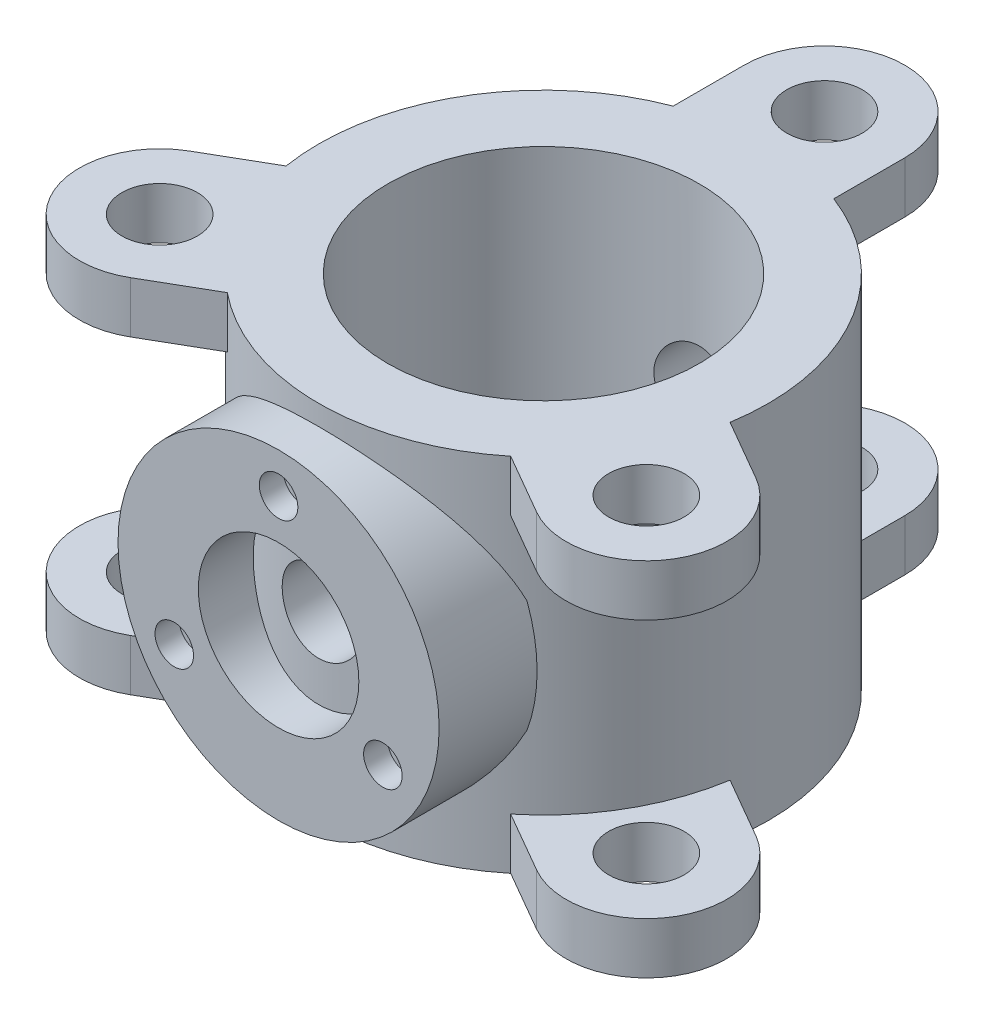
from build123d import *

# Parameters (mm, degrees)
SKETCH1_R            = 97
BOSS_EXTRUDE7_DEPTH  = 225
SKETCH1_5_R          = 23.5
BOSS_EXTRUDE9_DEPTH  = 32
SKETCH2_R            = 100
SKETCH2_R_2          = 50
BOSS_EXTRUDE11_DEPTH = 61
SKETCH2_4_R          = 12
CUT_EXTRUDE1_DEPTH   = 15
SKETCH2_5_R          = 25
CUT_EXTRUDE2_DEPTH   = 547


with BuildPart() as part:
    # Sketch1 → Boss-Extrude7 (new body)
    with BuildSketch(Plane(origin=(0, 0, 0), x_dir=(1, 0, 0), z_dir=(0, 1, 0))):
        with BuildLine():
            ThreePointArc((140, 0), (115.325625947, 79.372539332), (50, 130.766968306))
            ThreePointArc((50, 130.766968306), (0, 140), (-50, 130.766968306))
            ThreePointArc((-50, 130.766968306), (-121.24355653, 70), (-138.247516529, -22.082213964))
            ThreePointArc((-138.247516529, -22.082213964), (-121.24355653, -70), (-88.247516529, -108.684754342))
            ThreePointArc((-88.247516529, -108.684754342), (0, -140), (88.247516529, -108.684754342))
            ThreePointArc((88.247516529, -108.684754342), (121.24355653, -70), (138.247516529, -22.082213964))
            ThreePointArc((138.247516529, -22.082213964), (139.561191443, -11.075822451), (140, 0))
        make_face()
        Circle(SKETCH1_R, mode=Mode.SUBTRACT)
    extrude(amount=BOSS_EXTRUDE7_DEPTH)

    # Sketch1_5 → Boss-Extrude9 (add)
    # profile 1 of 3: a face of its own
    with BuildSketch(Plane(origin=(0, 0, 0), x_dir=(1, 0, 0), z_dir=(0, 1, 0))):
        with BuildLine():
            Line((50, 130.766968306), (50, 175))
            ThreePointArc((50, 175), (0, 225), (-50, 175))
            Line((-50, 175), (-50, 130.766968306))
            ThreePointArc((-50, 130.766968306), (0, 140), (50, 130.766968306))
        make_face()
        with Locations((0, 175)):
            Circle(SKETCH1_5_R, mode=Mode.SUBTRACT)
    # profile 2 of 3: a face of its own
    with BuildSketch(Plane(origin=(0, 0, 0), x_dir=(1, 0, 0), z_dir=(0, 1, 0))):
        with BuildLine():
            Line((176.554445662, -44.198729811), (138.247516529, -22.082213964))
            ThreePointArc((138.247516529, -22.082213964), (121.24355653, -70), (88.247516529, -108.684754342))
            Line((88.247516529, -108.684754342), (126.554445662, -130.801270189))
            ThreePointArc((126.554445662, -130.801270189), (194.855715852, -112.5), (176.554445662, -44.198729811))
        make_face()
        with Locations((151.554445662, -87.5)):
            Circle(SKETCH1_5_R, mode=Mode.SUBTRACT)
    # profile 3 of 3: a face of its own
    with BuildSketch(Plane(origin=(0, 0, 0), x_dir=(1, 0, 0), z_dir=(0, 1, 0))):
        with BuildLine():
            ThreePointArc((-88.247516529, -108.684754342), (-121.24355653, -70), (-138.247516529, -22.082213964))
            Line((-138.247516529, -22.082213964), (-176.554445662, -44.198729811))
            ThreePointArc((-176.554445662, -44.198729811), (-194.855715851, -112.5), (-126.554445662, -130.801270189))
            Line((-126.554445662, -130.801270189), (-88.247516529, -108.684754342))
        make_face()
        with Locations((-151.554445662, -87.5)):
            Circle(SKETCH1_5_R, mode=Mode.SUBTRACT)
    boss_extrude9 = extrude(amount=BOSS_EXTRUDE9_DEPTH)

    # Mirror1: Boss-Extrude9 across plane
    add(boss_extrude9.mirror(Plane.ZX.offset(112.5)))

    # Sketch2 → Boss-Extrude11 (add)
    with BuildSketch(Plane.XY.offset(165)):
        with Locations((0, 112.5)):
            Circle(SKETCH2_R)
        with Locations((0, 112.5)):
            Circle(SKETCH2_R_2, mode=Mode.SUBTRACT)
    extrude(amount=-BOSS_EXTRUDE11_DEPTH)

    # Sketch2_4 → Cut-Extrude1 (cut)
    with BuildSketch(Plane.XY.offset(165)):
        with Locations((0, 187.5)):
            Circle(SKETCH2_4_R)
        with Locations((64.951905284, 75)):
            Circle(SKETCH2_4_R)
        with Locations((-64.951905284, 75)):
            Circle(SKETCH2_4_R)
    extrude(amount=-CUT_EXTRUDE1_DEPTH, mode=Mode.SUBTRACT)

    # Sketch2_5 → Cut-Extrude2 (cut)
    with BuildSketch(Plane.XY.offset(165)):
        with Locations((0, 112.5)):
            Circle(SKETCH2_5_R)
    extrude(amount=-CUT_EXTRUDE2_DEPTH, mode=Mode.SUBTRACT)


solid = part.part
